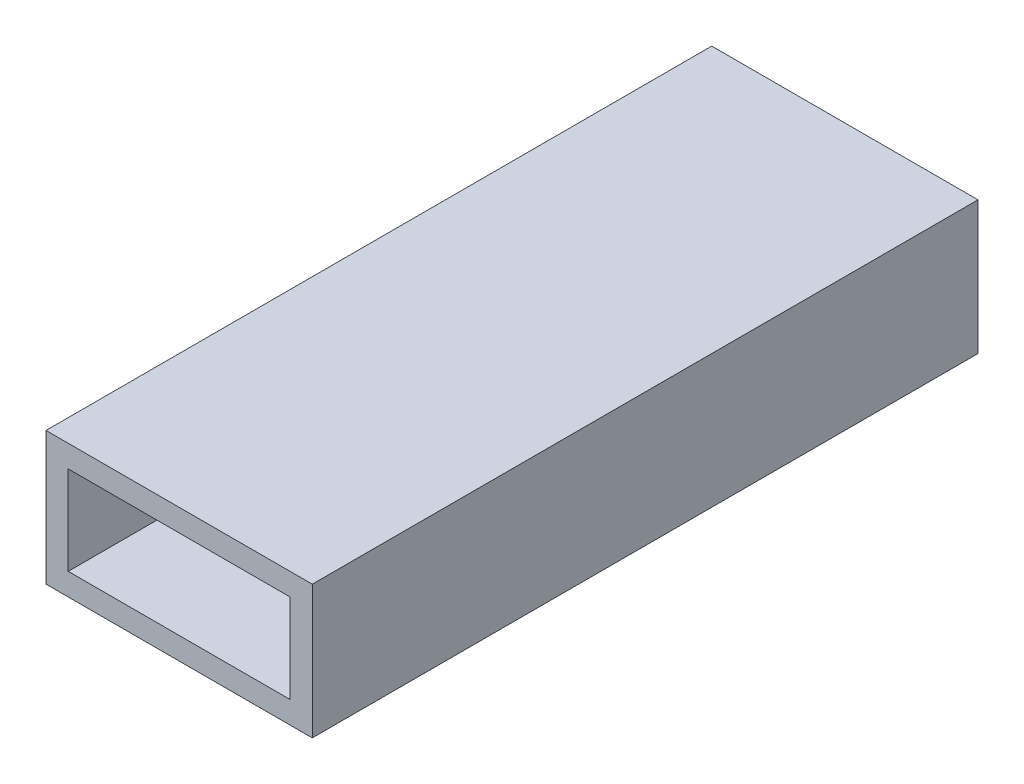
from build123d import *

# Parameters (mm, degrees)
ESQUISSE1_W                  = 60
ESQUISSE1_H                  = 150
BOSS_EXTRU_1_DEPTH           = 30
ESQUISSE2_W                  = 50
ESQUISSE2_H                  = 20
ENL_V_MAT_EXTRU_1_DEPTH      = 75
ENL_V_MAT_EXTRU_1_DEPTH_BACK = 70


with BuildPart() as part:
    # Esquisse1 → Boss.-Extru.1 (new body)
    with BuildSketch(Plane(origin=(0, 0, 0), x_dir=(1, 0, 0), z_dir=(0, 1, 0))):
        Rectangle(ESQUISSE1_W, ESQUISSE1_H)
    extrude(amount=BOSS_EXTRU_1_DEPTH)

    # Esquisse2 → Enlèv. mat.-Extru.1 (cut, two sides)
    with BuildSketch(Plane.XY) as enl_v_mat_extru_1_sk:
        with Locations((0, 15)):
            Rectangle(ESQUISSE2_W, ESQUISSE2_H)
    extrude(amount=ENL_V_MAT_EXTRU_1_DEPTH, mode=Mode.SUBTRACT)
    extrude(enl_v_mat_extru_1_sk.sketch, amount=-ENL_V_MAT_EXTRU_1_DEPTH_BACK, mode=Mode.SUBTRACT)


solid = part.part
